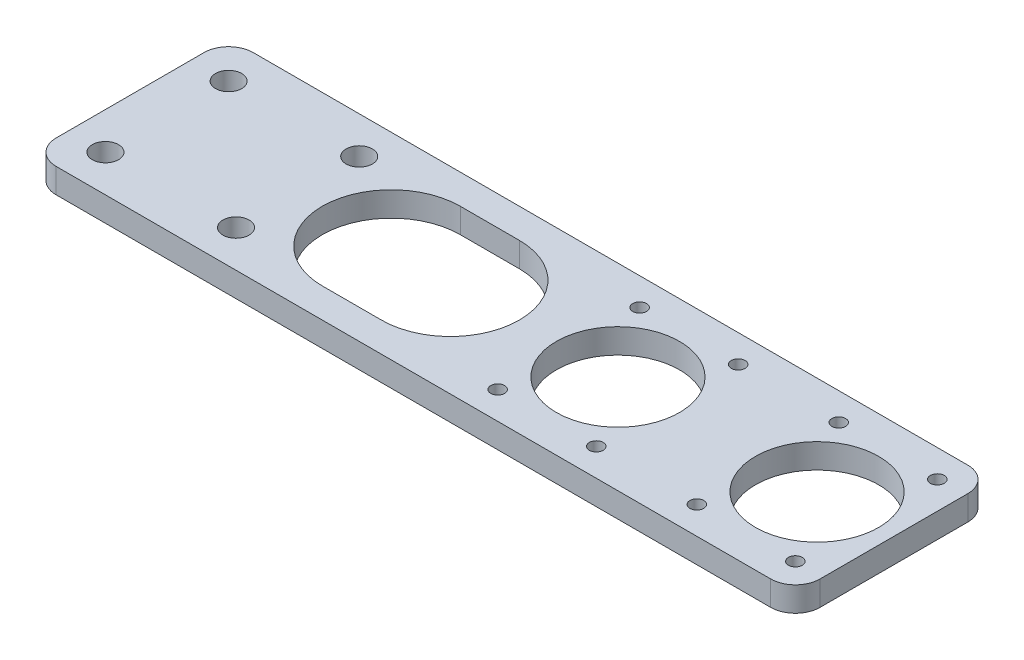
from build123d import *

# Parameters (mm, degrees)
SKETCH1_R                   = 15.875
SKETCH1_R_2                 = 1.778
BOSS_EXTRUDE1_DEPTH         = 6.35
F_1_4_CLEARANCE_HOLE2_D     = 6.7564
F_1_4_CLEARANCE_HOLE2_DEPTH = 6.35
FILLET1_R                   = 6.35


with BuildPart() as part:
    # Sketch1 → Boss-Extrude1 (new body)
    with BuildSketch(Plane(origin=(0, 0, 0), x_dir=(1, 0, 0), z_dir=(0, 1, 0))):
        with BuildLine():
            Line((-113.03, 25.4), (-113.03, -25.4))
            Line((-113.03, -25.4), (77.47, -25.4))
            ThreePointArc((77.47, -25.4), (81.960128061, -23.540128061), (83.82, -19.05))
            Line((83.82, -19.05), (83.82, 19.05))
            ThreePointArc((83.82, 19.05), (81.960128061, 23.540128061), (77.47, 25.4))
            Line((77.47, 25.4), (-113.03, 25.4))
        make_face()
        with Locations((12.7, 0)):
            Circle(SKETCH1_R, mode=Mode.SUBTRACT)
        with Locations((64.008, 0)):
            Circle(SKETCH1_R, mode=Mode.SUBTRACT)
        with Locations((0, 18.288)):
            Circle(SKETCH1_R_2, mode=Mode.SUBTRACT)
        with Locations((25.4, 18.288)):
            Circle(SKETCH1_R_2, mode=Mode.SUBTRACT)
        with Locations((51.308, 18.288)):
            Circle(SKETCH1_R_2, mode=Mode.SUBTRACT)
        with Locations((76.708, 18.288)):
            Circle(SKETCH1_R_2, mode=Mode.SUBTRACT)
        with Locations((0, -18.288)):
            Circle(SKETCH1_R_2, mode=Mode.SUBTRACT)
        with Locations((25.4, -18.288)):
            Circle(SKETCH1_R_2, mode=Mode.SUBTRACT)
        with Locations((51.308, -18.288)):
            Circle(SKETCH1_R_2, mode=Mode.SUBTRACT)
        with Locations((76.708, -18.288)):
            Circle(SKETCH1_R_2, mode=Mode.SUBTRACT)
        with BuildLine():
            Line((-30.48, 17.78), (-45.72, 17.78))
            ThreePointArc((-45.72, 17.78), (-63.5, 0), (-45.72, -17.78))
            Line((-45.72, -17.78), (-30.48, -17.78))
            ThreePointArc((-30.48, -17.78), (-12.7, 0), (-30.48, 17.78))
        make_face(mode=Mode.SUBTRACT)
    extrude(amount=BOSS_EXTRUDE1_DEPTH)

    # 1/4 Clearance Hole2
    with Locations(Plane(origin=(0, 6.35, 0), x_dir=(1, 0, 0), z_dir=(0, 1, 0))):
        with Locations((-103.505, 15.875), (-69.85, 15.875), (-69.85, -15.875), (-103.505, -15.875)):
            Hole(F_1_4_CLEARANCE_HOLE2_D / 2, depth=F_1_4_CLEARANCE_HOLE2_DEPTH)

    # Fillet1
    fillet1_edges = [part.edges().sort_by_distance(p)[0] for p in [
        (-113.03, 3.175, 25.4),
        (-113.03, 3.175, -25.4),
    ]]
    fillet(fillet1_edges, radius=FILLET1_R)


solid = part.part
